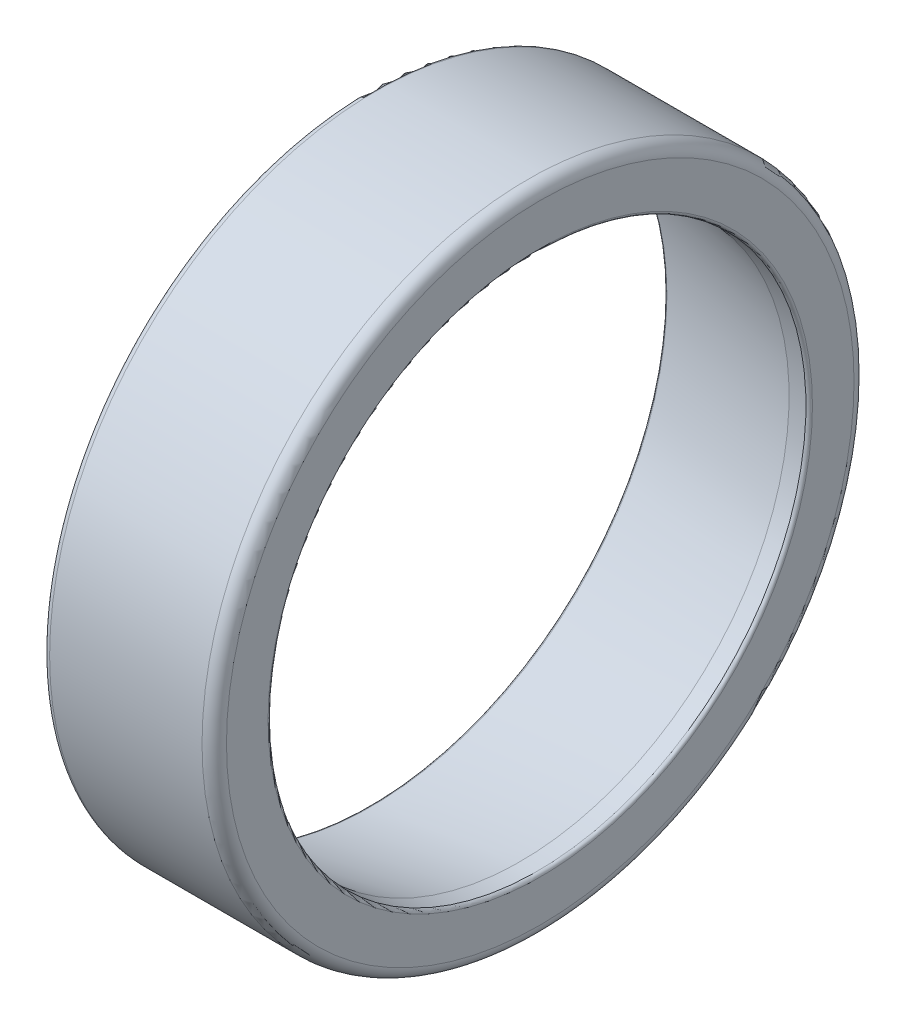
from build123d import *

# Parameters (mm, degrees)
FILLET1_R = 1.5
FILLET2_R = 0.8
FILLET3_R = 0.4


with BuildPart() as part:
    # Sketch1 → Revolve1 (revolve)
    with BuildSketch(Plane.XY):
        Polygon((22, 33), (22, 40), (1, 40), (1, 36.267672581), (19.5318921, 33), align=None)
    revolve(axis=Axis((0, 0, 0), (1, 0, 0)))

    # Fillet1
    fillet1_edges = [part.edges().sort_by_distance(p)[0] for p in [
        (22, -40, 0),
    ]]
    fillet(fillet1_edges, radius=FILLET1_R)

    # Fillet2
    fillet2_edges = [part.edges().sort_by_distance(p)[0] for p in [
        (1, -40, 0),
    ]]
    fillet(fillet2_edges, radius=FILLET2_R)

    # Fillet3
    fillet3_edges = [part.edges().sort_by_distance(p)[0] for p in [
        (22, -33, 0),
        (1, -36.267672581, 0),
    ]]
    fillet(fillet3_edges, radius=FILLET3_R)


solid = part.part
